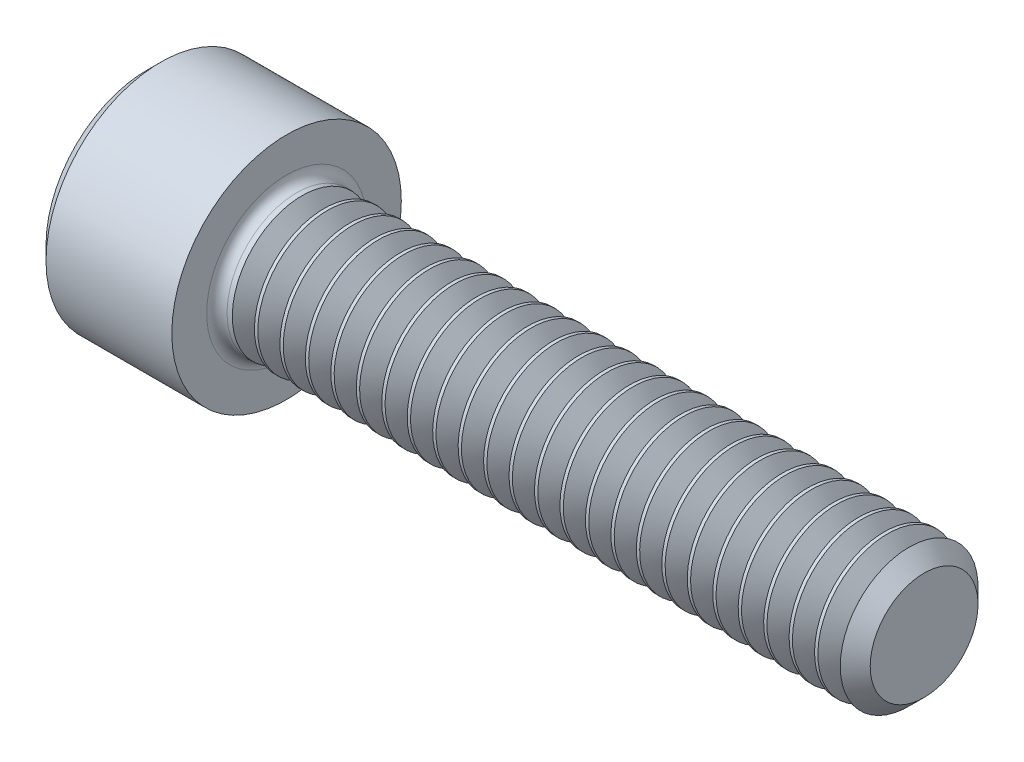
from build123d import *

# Parameters (mm, degrees)
FILLET1_R       = 0.3048
HEX_2_DEPTH     = 1.9558
THDSCHPAT_COUNT = 24
THDSCHPAT_PITCH = 0.76073


with BuildPart() as part:
    # BodySke → Base-Revolve (revolve)
    with BuildSketch(Plane.XY):
        Polygon((0, 0), (0, 3.0226), (0.4064, 3.429), (4.1656, 3.429), (4.1656, 2.0828), (22.74316, 2.0828), (23.2156, 1.61036), (23.2156, 0), align=None)
    revolve(axis=Axis((-31.75, 0, 0), (1, 0, 0)))

    # Fillet1
    fillet1_edges = [part.edges().sort_by_distance(p)[0] for p in [
        (4.1656, -2.0828, 0),
    ]]
    fillet(fillet1_edges, radius=FILLET1_R)

    # Sketch2 → Hex-PreBroach (revolve, cut)
    with BuildSketch(Plane.XY):
        Polygon((0, 1.778), (1.9558, 1.778), (2.982328779, 0), (0, 0), align=None)
    revolve(axis=Axis((0, 0, 0), (1, 0, 0)), mode=Mode.SUBTRACT)

    # Sketch3 → Hex 2 (cut)
    with BuildSketch(Plane(origin=(0, 0, 0), x_dir=(0, 0.5, 0.866025404), z_dir=(-1, 0, 0))):
        Polygon((1.026528779, 1.778), (-1.026528779, 1.778), (-2.053057557, 0), (-1.026528779, -1.778), (1.026528779, -1.778), (2.053057557, 0), align=None)
    extrude(amount=-HEX_2_DEPTH, mode=Mode.SUBTRACT)

    # ThdSchSke → ThreadSchematic (revolve, cut)
    with BuildSketch(Plane.XY):
        Polygon((4.95808, -1.61036), (4.627273951, -2.0828), (4.627273951, -2.6035), (5.288886049, -2.6035), (5.288886049, -2.0828), align=None)
    threadschematic = revolve(axis=Axis((-3.175, 0, 0), (1, 0, 0)), mode=Mode.SUBTRACT)

    # ThdSchPat: ThreadSchematic ×24
    with Locations(*[(i * THDSCHPAT_PITCH, 0, 0) for i in range(1, THDSCHPAT_COUNT)]):
        add(threadschematic, mode=Mode.SUBTRACT)


solid = part.part
